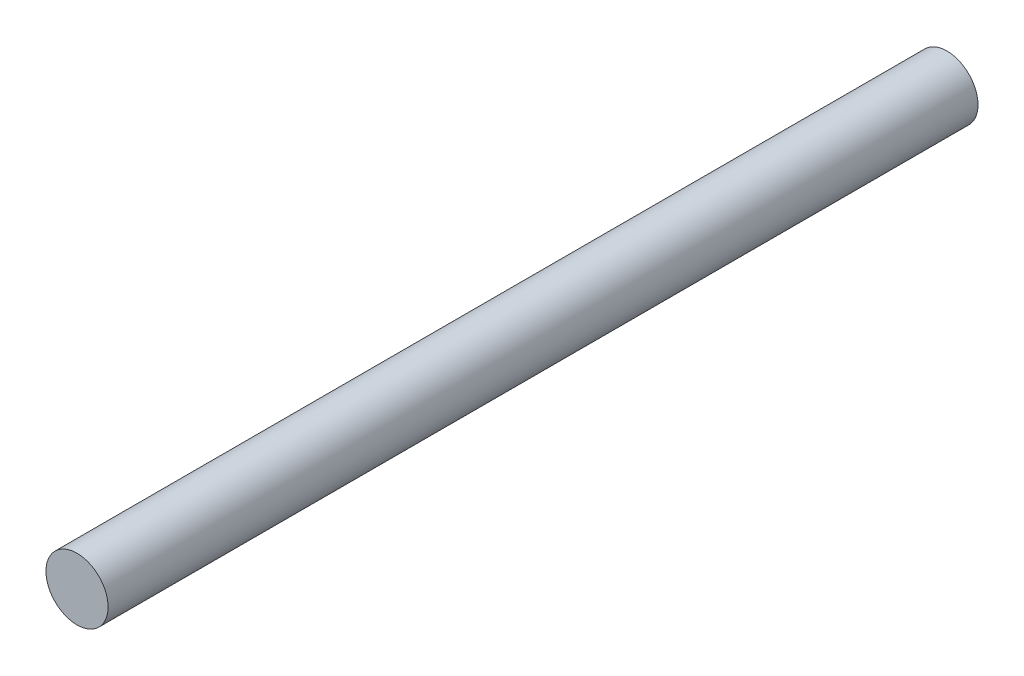
from build123d import *

# Parameters (mm, degrees)
SKETCH1_R           = 5
BOSS_EXTRUDE1_DEPTH = 140


with BuildPart() as part:
    # Sketch1 → Boss-Extrude1 (new body)
    with BuildSketch(Plane.XY):
        Circle(SKETCH1_R)
    extrude(amount=BOSS_EXTRUDE1_DEPTH)


solid = part.part
